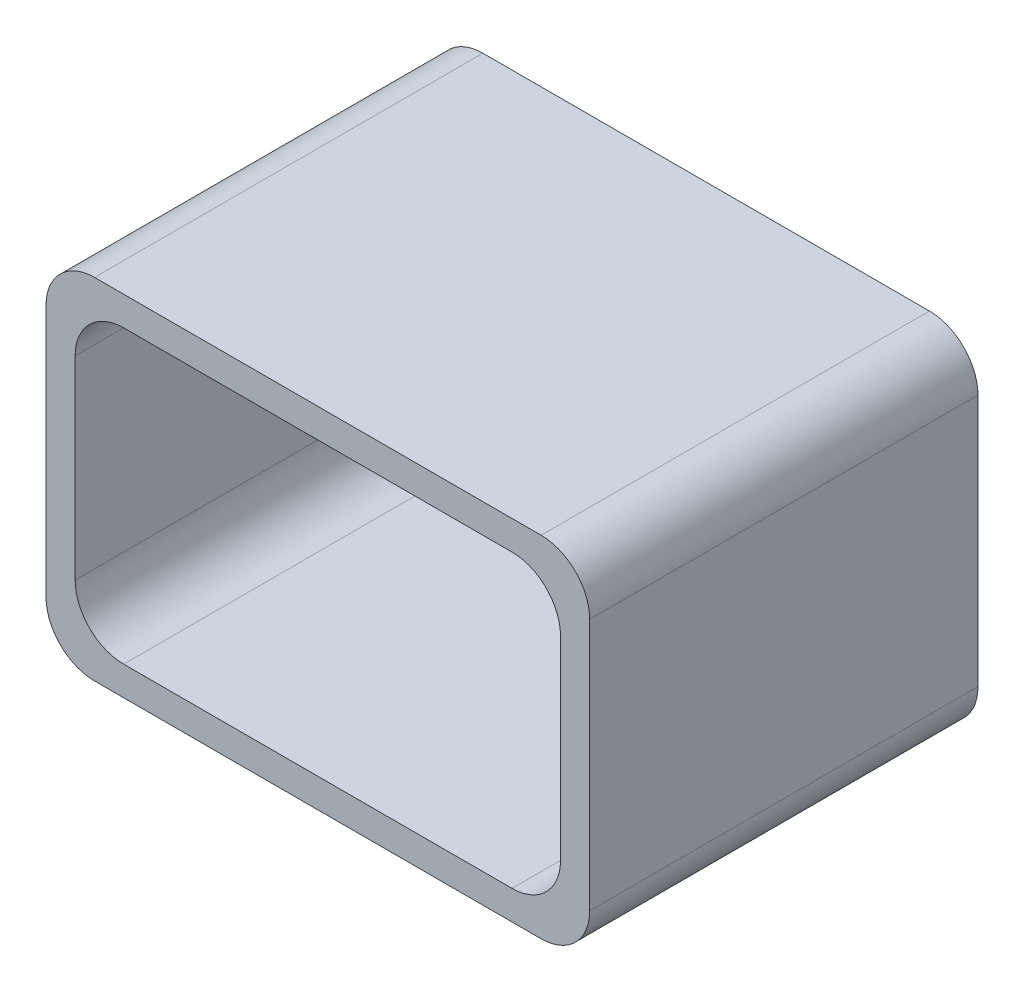
from build123d import *

# Parameters (mm, degrees)
SKETCH1_W           = 0.56
SKETCH1_H           = 0.36
SKETCH1_W_2         = 0.5
SKETCH1_H_2         = 0.3
BOSS_EXTRUDE1_DEPTH = 0.4
FILLET1_R           = 0.05


with BuildPart() as part:
    # Sketch1 → Boss-Extrude1 (new body)
    with BuildSketch(Plane.XY):
        with Locations((0.28, 0.18)):
            Rectangle(SKETCH1_W, SKETCH1_H)
        with Locations((0.28, 0.18)):
            Rectangle(SKETCH1_W_2, SKETCH1_H_2, mode=Mode.SUBTRACT)
    extrude(amount=BOSS_EXTRUDE1_DEPTH)

    # Fillet1
    fillet1_edges = [part.edges().sort_by_distance(p)[0] for p in [
        (0.03, 0.33, 0.2),
        (0.03, 0.03, 0.2),
        (0.53, 0.03, 0.2),
        (0.53, 0.33, 0.2),
        (0, 0.36, 0.2),
        (0.56, 0.36, 0.2),
        (0.56, 0, 0.2),
        (0, 0, 0.2),
    ]]
    fillet(fillet1_edges, radius=FILLET1_R)


solid = part.part
